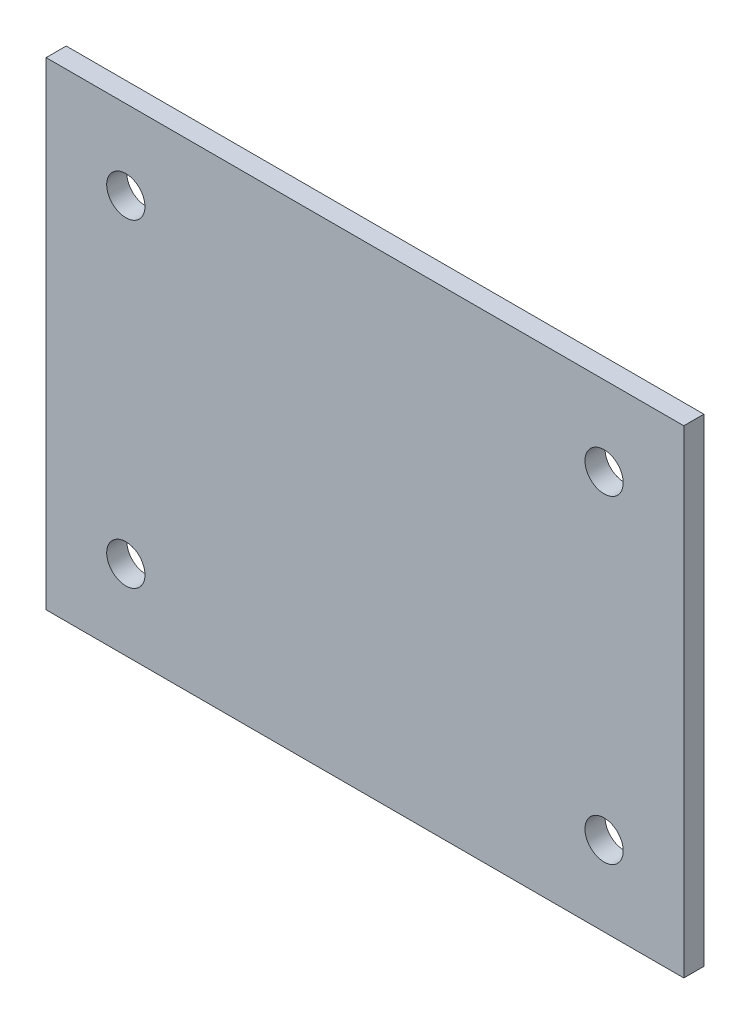
from build123d import *

# Parameters (mm, degrees)
SKETCH1_W            = 50.8
SKETCH1_H            = 38.1
EXTRUDE1_DEPTH       = 1.6002
SKETCH2_R            = 1.524
CUT_EXTRUDE1_DEPTH   = 1.6002
LPATTERN1_COUNT      = 2
LPATTERN1_PITCH      = 38.1
LPATTERN1_COUNT_DIR2 = 2
LPATTERN1_PITCH_DIR2 = 25.4


with BuildPart() as part:
    # Sketch1 → Extrude1 (new body)
    with BuildSketch(Plane.XY):
        with Locations((25.4, -19.05)):
            Rectangle(SKETCH1_W, SKETCH1_H)
    extrude(amount=EXTRUDE1_DEPTH)

    # Sketch2 → Cut-Extrude1 (cut)
    with BuildSketch(Plane.XY.offset(1.6002)):
        with Locations((6.35, -6.35)):
            Circle(SKETCH2_R)
    cut_extrude1 = extrude(amount=-CUT_EXTRUDE1_DEPTH, mode=Mode.SUBTRACT)

    # LPattern1: Cut-Extrude1 2 × 2
    with Locations(*[(i * LPATTERN1_PITCH, -j * LPATTERN1_PITCH_DIR2, 0) for i in range(LPATTERN1_COUNT) for j in range(LPATTERN1_COUNT_DIR2) if (i, j) != (0, 0)]):
        add(cut_extrude1, mode=Mode.SUBTRACT)


solid = part.part
